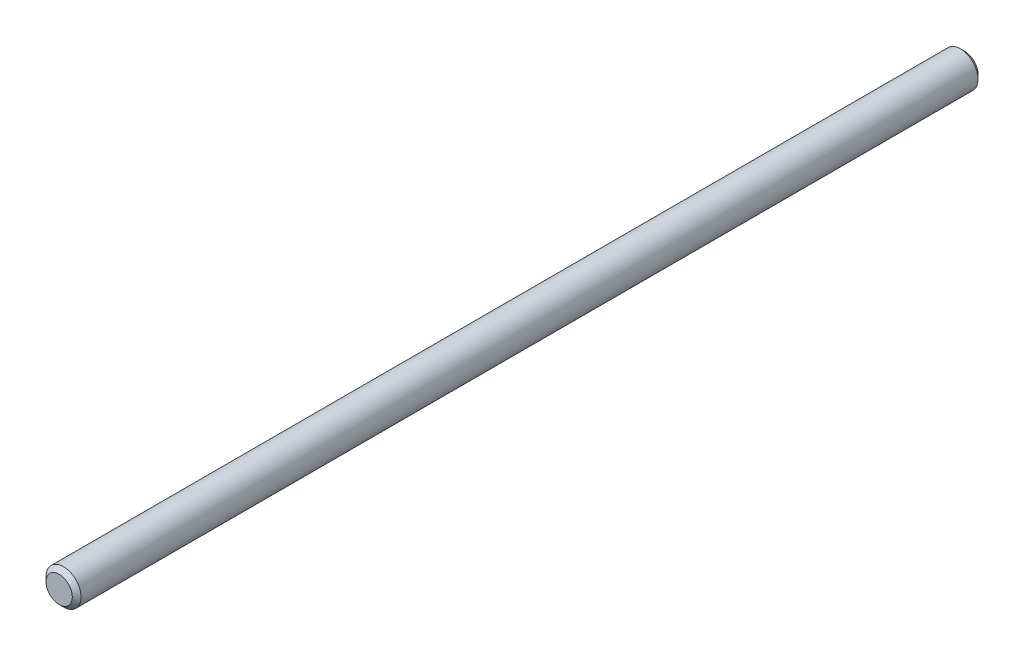
from build123d import *

# Parameters (mm, degrees)
SKETCH1_R           = 6
BOSS_EXTRUDE1_DEPTH = 310
CHAMFER1_SIZE       = 1.5


with BuildPart() as part:
    # Sketch1 → Boss-Extrude1 (new body)
    with BuildSketch(Plane.XY):
        Circle(SKETCH1_R)
    extrude(amount=BOSS_EXTRUDE1_DEPTH)

    # Chamfer1
    chamfer1_edges = [part.edges().sort_by_distance(p)[0] for p in [
        (-6, 0, 310),
        (-6, 0, 0),
    ]]
    chamfer(chamfer1_edges, length=CHAMFER1_SIZE)


solid = part.part
